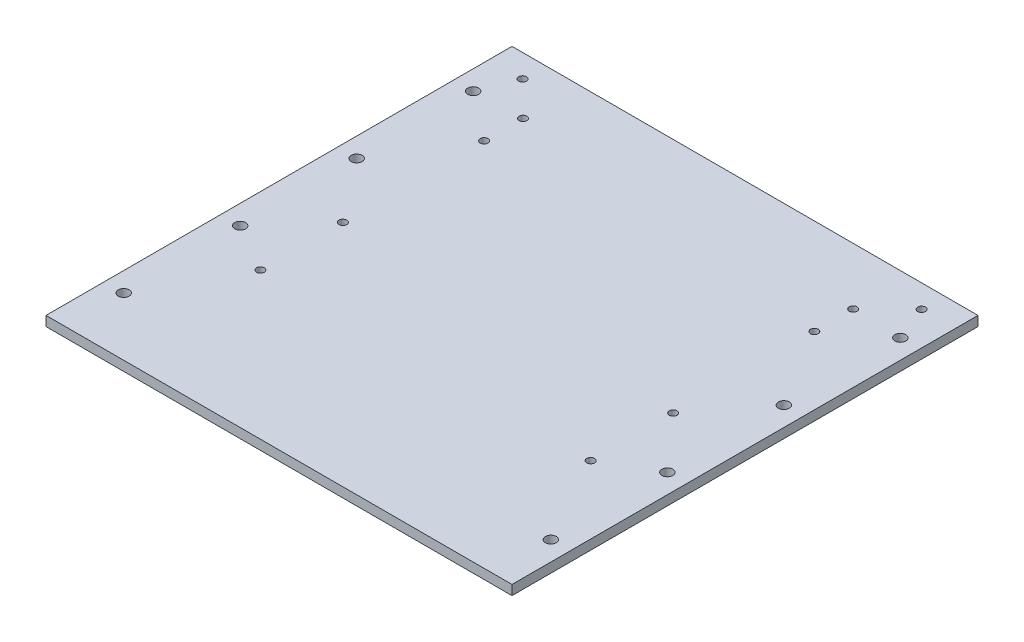
from build123d import *

# Parameters (mm, degrees)
SKETCH1_W               = 152.4
SKETCH1_H               = 304.8
BOSS_EXTRUDE1_DEPTH     = 6.35
F_1_4_20_TAPPED_HOLE1_D = 5.1054
LPATTERN1_COUNT         = 4
LPATTERN1_PITCH         = 76.2


with BuildPart() as part:
    # Sketch1 → Boss-Extrude1 (new body)
    with BuildSketch(Plane(origin=(0, 0, 0), x_dir=(1, 0, 0), z_dir=(0, 1, 0))):
        with Locations((76.2, 0)):
            Rectangle(SKETCH1_W, SKETCH1_H)
    extrude(amount=BOSS_EXTRUDE1_DEPTH)

    # 1/4-20 Tapped Hole1 (through all)
    with Locations(Plane(origin=(0, 6.35, 0), x_dir=(1, 0, 0), z_dir=(0, 1, 0))):
        with Locations((130.5, 137.4), (108, 115.175), (108, -2.6), (108, -56.575), (108, 89.775)):
            Hole(F_1_4_20_TAPPED_HOLE1_D / 2)

    # Sketch4 → 1/4 Clearance Hole2 (revolve, cut)
    with BuildSketch(Plane(origin=(139.7, 6.35, -114.3), x_dir=(0, 0, 1), z_dir=(1, 0, 0))):
        Polygon((0, 0), (0, 14.845817477), (3.57124, 12.7), (3.57124, 0), align=None)
    f_1_4_clearance_hole2 = revolve(axis=Axis((139.7, 12.7, -114.3), (0, -1, 0)), mode=Mode.SUBTRACT)

    # LPattern1: 1/4 Clearance Hole2 ×4
    with Locations(*[(0, 0, i * LPATTERN1_PITCH) for i in range(1, LPATTERN1_COUNT)]):
        add(f_1_4_clearance_hole2, mode=Mode.SUBTRACT)

    # Mirror1: part across plane


with BuildPart() as part_1:
    add(part.part)
    add(part.part.mirror(Plane(origin=(0, 0, 0), x_dir=(0, 0, 1), z_dir=(1, 0, 0))))


solid = part_1.part
